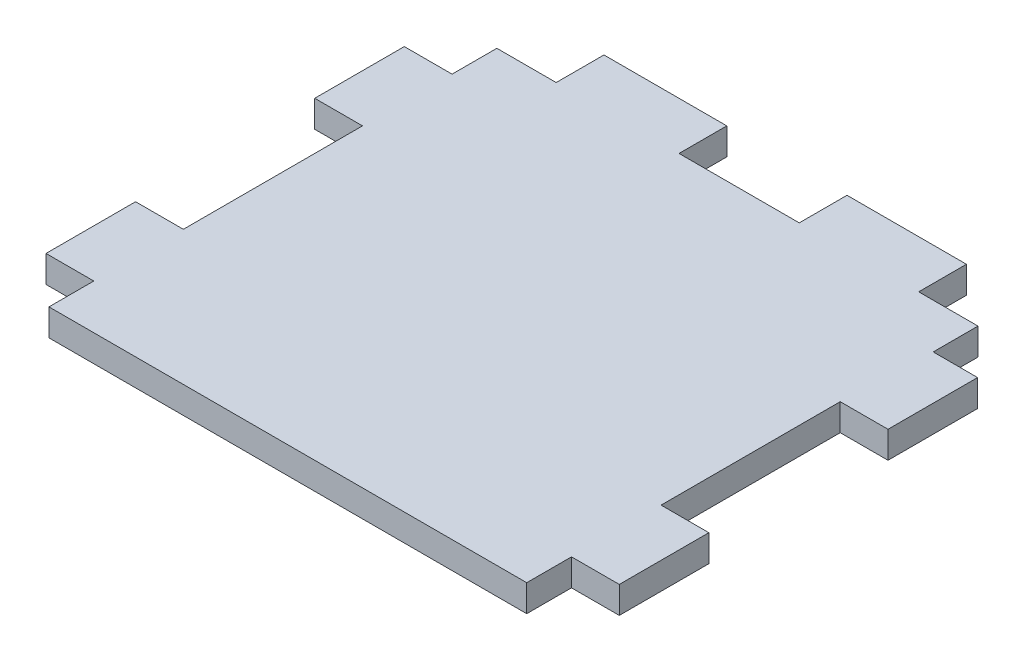
from build123d import *

# Parameters (mm, degrees)
BOSS_EXTRUDE1_DEPTH = 4.5


with BuildPart() as part:
    # Sketch1 → Boss-Extrude1 (new body)
    with BuildSketch(Plane(origin=(0, 0, 0), x_dir=(1, 0, 0), z_dir=(0, 1, 0))):
        Polygon((-30.066262521, 37.5), (-40, 37.5), (-40, 30), (-48, 30), (-48, 15), (-40, 15), (-40, 12.5), (-40, -15), (-48, -15), (-48, -30), (-40, -30), (-40, -32.5), (-40, -34.271597524), (-40, -37.5), (40, -37.5), (40, -32.5), (40, -30), (48, -30), (48, -17.5), (48, -15), (40, -15), (40, 12.5), (40, 15), (48, 15), (48, 30), (40.57, 30), (40.57, 37.5), (30.636262521, 37.5), (30.636262521, 45.5), (10.636262521, 45.5), (10.636262521, 37.5), (-9.496262521, 37.5), (-9.496262521, 45.5), (-30.066262521, 45.5), align=None)
    extrude(amount=-BOSS_EXTRUDE1_DEPTH)


solid = part.part
